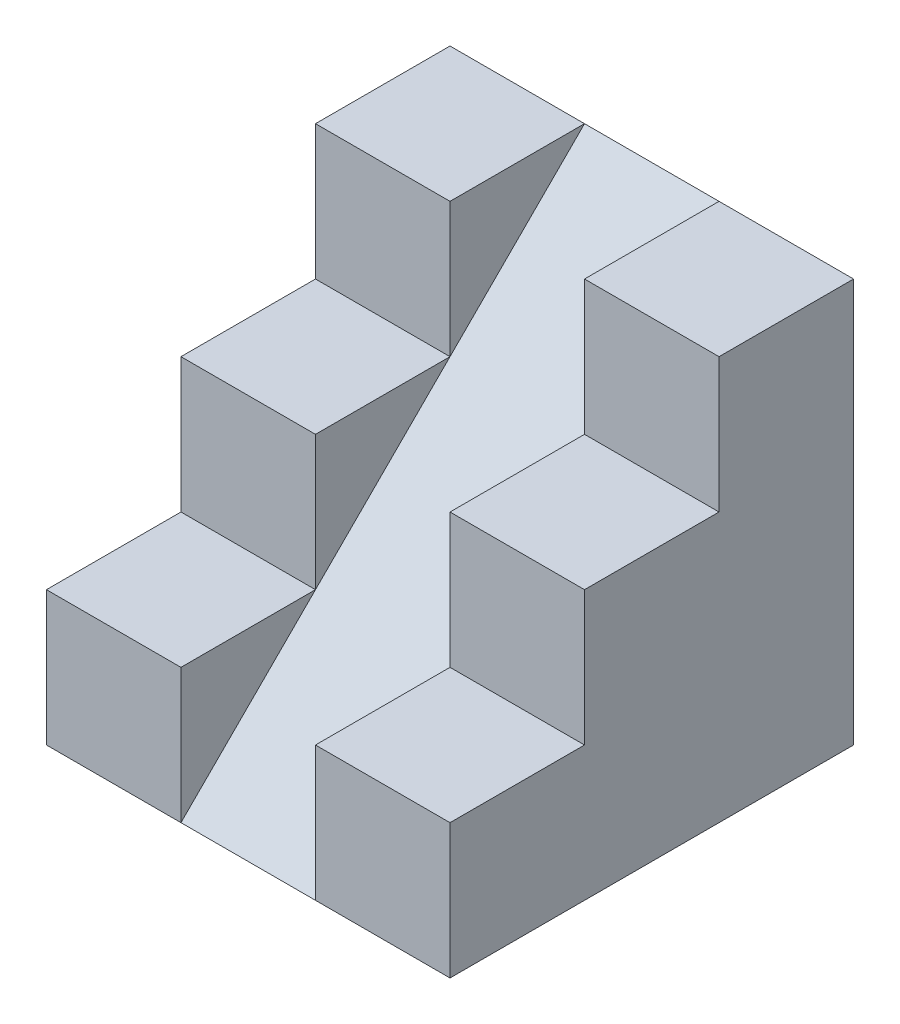
from build123d import *

# Parameters (mm, degrees)
SALIENTE_EXTRUIR1_DEPTH = 30
CORTAR_EXTRUIR1_DEPTH   = 10


with BuildPart() as part:
    # Croquis1 → Saliente-Extruir1 (new body, symmetric)
    with BuildSketch(Plane(origin=(0, 0, 0), x_dir=(0, 0, -1), z_dir=(1, 0, 0))):
        Polygon((0, 0), (-60, 0), (-60, 20), (-40, 20), (-40, 40), (-20, 40), (-20, 60), (0, 60), align=None)
    extrude(amount=SALIENTE_EXTRUIR1_DEPTH, both=True)

    # Croquis2 → Cortar-Extruir1 (cut, symmetric)
    with BuildSketch(Plane(origin=(0, 0, 0), x_dir=(0, 0, -1), z_dir=(1, 0, 0))):
        Polygon((-40, 20), (-20, 40), (-40, 40), align=None)
        Polygon((-60, 0), (-40, 20), (-60, 20), align=None)
        Polygon((-20, 40), (0, 60), (-20, 60), align=None)
    extrude(amount=CORTAR_EXTRUIR1_DEPTH, both=True, mode=Mode.SUBTRACT)


solid = part.part
